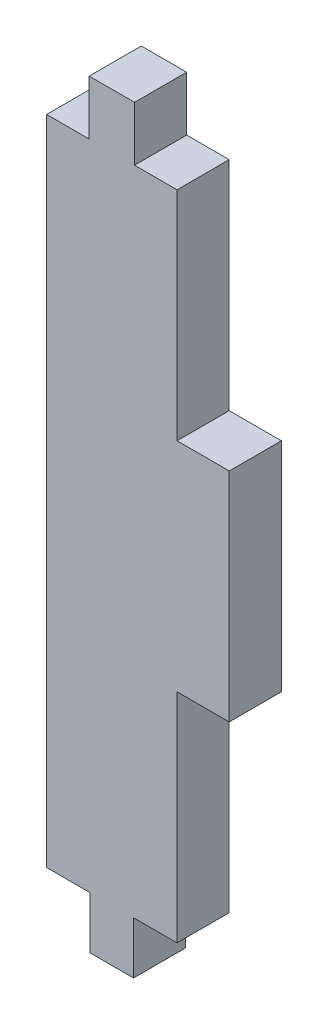
from build123d import *

# Parameters (mm, degrees)
SKETCH1_W           = 3.479672362
SKETCH1_H           = 8.35121367
SKETCH1_W_2         = 10
SKETCH1_H_2         = 50
SKETCH1_W_3         = 3.333333334
SKETCH1_H_3         = 8
SKETCH1_W_4         = 4
SKETCH1_H_4         = 16.666666667
BOSS_EXTRUDE1_DEPTH = 4


with BuildPart() as part:
    # Sketch1 → Boss-Extrude1 (new body)
    with BuildSketch(Plane.XY):
        with Locations((-32.230609748, -16.180003411)):
            Rectangle(SKETCH1_W, SKETCH1_H)
        with Locations((-32.230609748, -41.180003411)):
            Rectangle(SKETCH1_W_2, SKETCH1_H_2)
        with Locations((-32.230609748, -66.180003411)):
            Rectangle(SKETCH1_W_3, SKETCH1_H_3)
        with Locations((-25.230609748, -41.18000341)):
            Rectangle(SKETCH1_W_4, SKETCH1_H_4)
    extrude(amount=BOSS_EXTRUDE1_DEPTH)


solid = part.part
